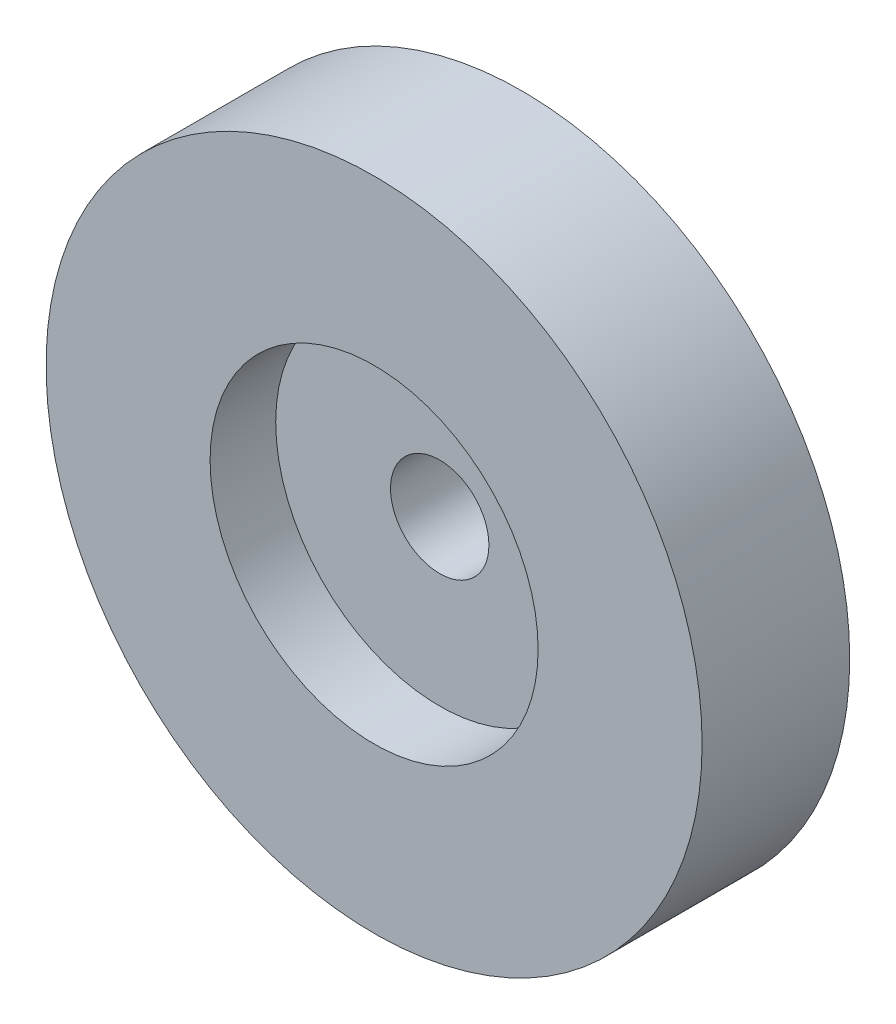
from build123d import *


with BuildPart() as part:
    # Esquisse2 → Révolution1 (revolve)
    with BuildSketch(Plane(origin=(0, 0, 0), x_dir=(1, 0, 0), z_dir=(0, 1, 0))):
        Polygon((20, 8), (20, 0), (40, 0), (40, 18), (6, 18), (6, 8), align=None)
    revolve(axis=Axis((0, 0, 0), (0, 0, -1)))


solid = part.part
